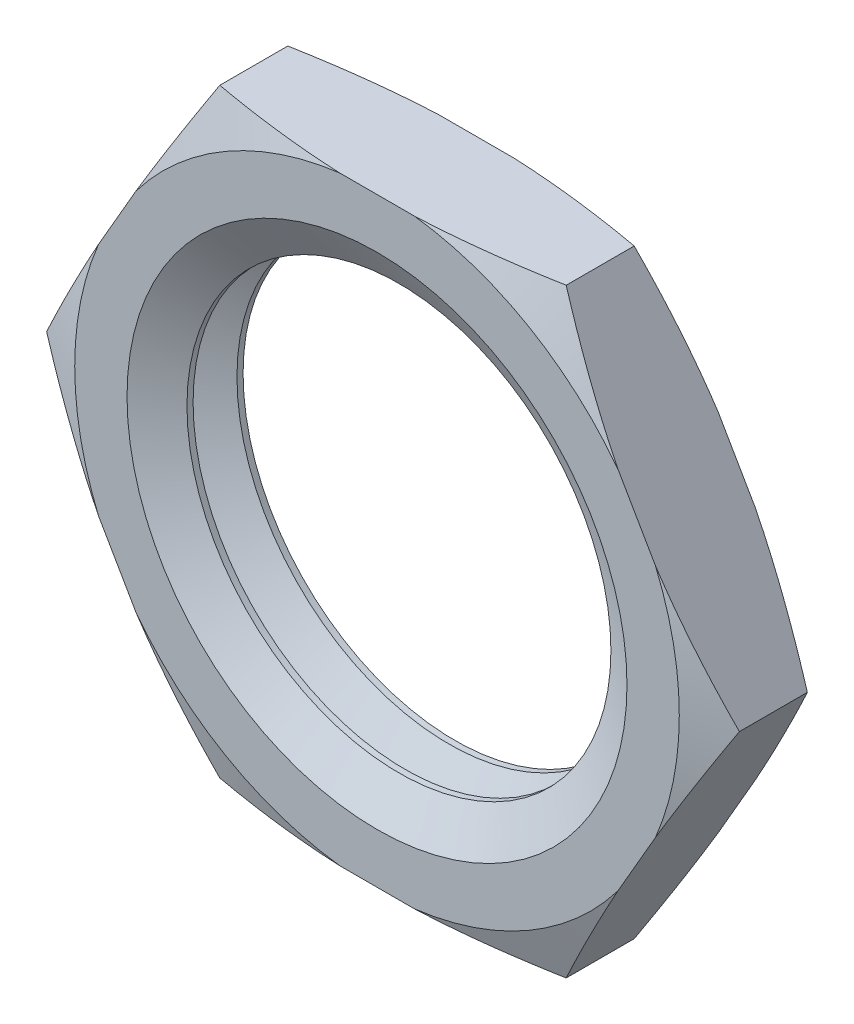
from build123d import *

# Parameters (mm, degrees)
BASE_EXTRUDE_DEPTH = 1.5875
SKETCH2_R          = 3.3655
CUT_EXTRUDE1_DEPTH = 2.5875
LPATTERN1_COUNT    = 3
LPATTERN1_PITCH    = 0.79375


with BuildPart() as part:
    # Sketch1 → Base-Extrude (new body)
    with BuildSketch(Plane.XY):
        Polygon((5.499261314, 0), (2.749630657, 4.7625), (-2.749630657, 4.7625), (-5.499261314, 0), (-2.749630657, -4.7625), (2.749630657, -4.7625), align=None)
    extrude(amount=BASE_EXTRUDE_DEPTH)

    # Sketch2 → Cut-Extrude1 (cut, through all)
    with BuildSketch(Plane.XY.offset(1.5875)):
        Circle(SKETCH2_R)
    extrude(amount=-CUT_EXTRUDE1_DEPTH, mode=Mode.SUBTRACT)

    # Sketch3 → Cut-Revolve1 (revolve, cut)
    with BuildSketch(Plane(origin=(0, 0, 0), x_dir=(0, 0, 1), z_dir=(-0.866025404, 0.5, 0))):
        Polygon((1.3335, 5.499261314), (1.5875, 5.499261314), (1.5875, 4.799261314), align=None)
    cut_revolve1 = revolve(axis=Axis((0, 0, 0), (0, 0, 1)), mode=Mode.SUBTRACT)

    # Mirror1: Cut-Revolve1 across plane
    add(cut_revolve1.mirror(Plane.XY.offset(0.79375)), mode=Mode.SUBTRACT)

    # Sketch4 → Cut-Revolve2 (revolve, cut)
    with BuildSketch(Plane(origin=(0, 0, 0), x_dir=(0, 0, 1), z_dir=(-0.866025404, 0.5, 0))):
        Polygon((1.5875, 3.96875), (1.190625, 3.281342336), (1.984375, 3.281342336), align=None)
    cut_revolve2 = revolve(axis=Axis((0, 0, 0), (0, 0, 1)), mode=Mode.SUBTRACT)

    # LPattern1: Cut-Revolve2 ×3
    with Locations(*[(0, 0, -i * LPATTERN1_PITCH) for i in range(1, LPATTERN1_COUNT)]):
        add(cut_revolve2, mode=Mode.SUBTRACT)


solid = part.part
